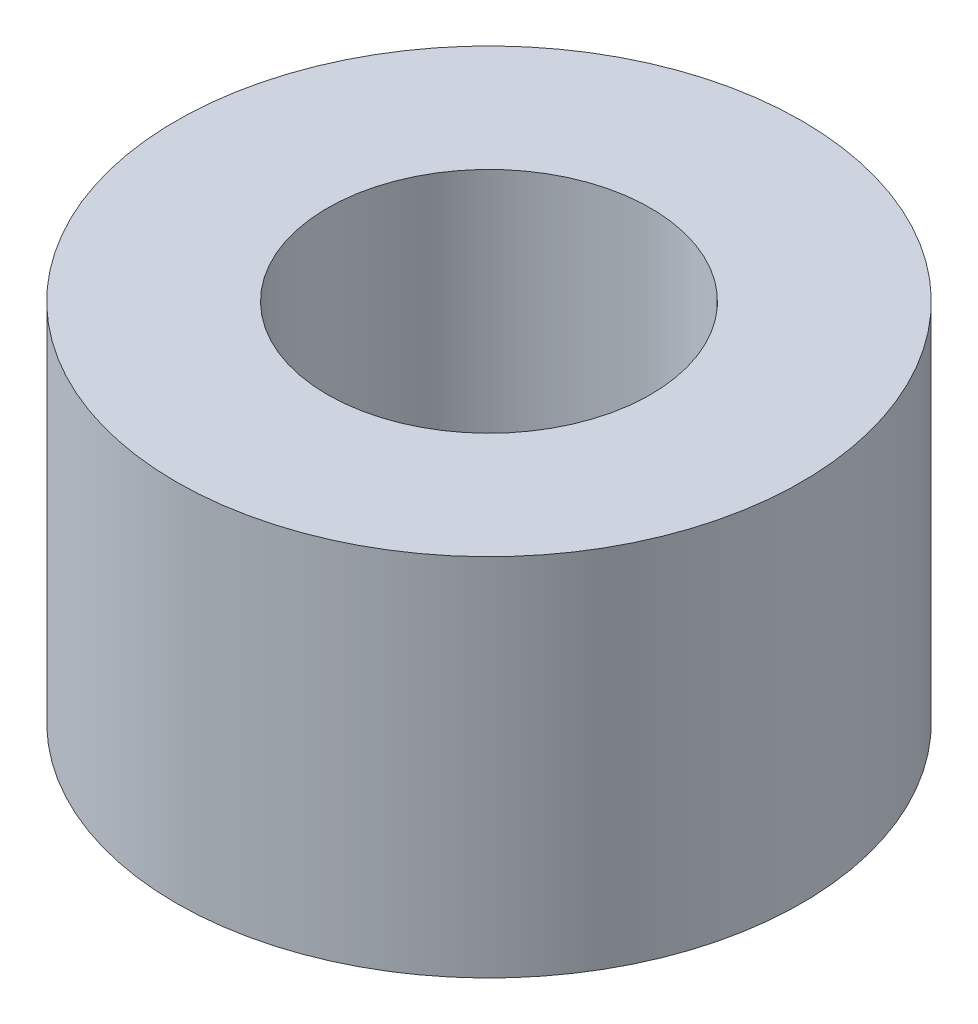
from build123d import *

# Parameters (mm, degrees)
SKETCH_1_R      = 3
SKETCH_1_R_2    = 1.55
EXTRUDE_1_DEPTH = 3.5


with BuildPart() as part:
    # 草图1 → 凸台-拉伸1 (new body)
    with BuildSketch(Plane(origin=(0, 0, 0), x_dir=(1, 0, 0), z_dir=(0, 1, 0))):
        Circle(SKETCH_1_R)
        Circle(SKETCH_1_R_2, mode=Mode.SUBTRACT)
    extrude(amount=EXTRUDE_1_DEPTH)


solid = part.part
